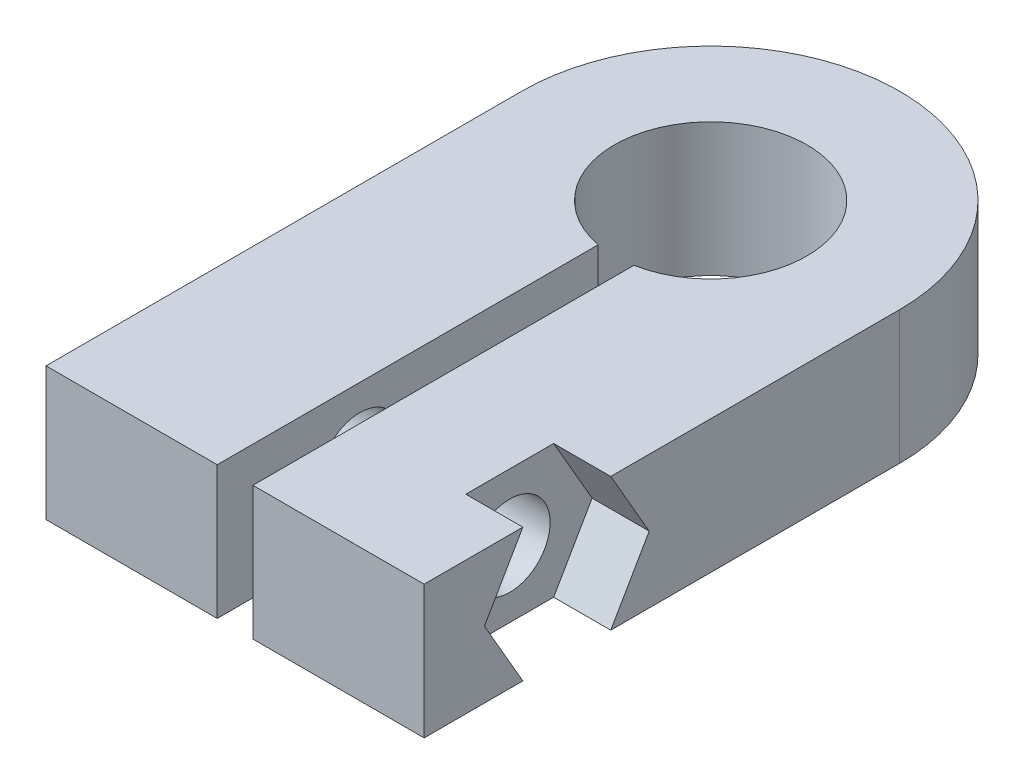
from build123d import *

# Parameters (mm, degrees)
BOSS_EXTRUDE1_DEPTH = 5.6
SKETCH2_R           = 1.7
CUT_EXTRUDE1_DEPTH  = 16.9
CUT_EXTRUDE2_DEPTH  = 2.4


with BuildPart() as part:
    # Sketch1 → Boss-Extrude1 (new body)
    with BuildSketch(Plane(origin=(0, 0, 0), x_dir=(1, 0, 0), z_dir=(0, 1, 0))):
        with BuildLine():
            Line((-7.95, -20), (-7.95, 0))
            ThreePointArc((-7.95, 0), (0, 7.95), (7.95, 0))
            Line((7.95, 0), (7.95, -20))
            Line((7.95, -20), (0.75, -20))
            Line((0.75, -20), (0.75, -3.979949748))
            ThreePointArc((0.75, -3.979949748), (0, 4.05), (-0.75, -3.979949748))
            Line((-0.75, -3.979949748), (-0.75, -20))
            Line((-0.75, -20), (-7.95, -20))
        make_face()
    extrude(amount=BOSS_EXTRUDE1_DEPTH)

    # Sketch2 → Cut-Extrude1 (cut, through all)
    with BuildSketch(Plane.ZY.offset(7.95)):
        with Locations((14, 2.8)):
            Circle(SKETCH2_R)
    extrude(amount=-CUT_EXTRUDE1_DEPTH, mode=Mode.SUBTRACT)

    # Sketch4 → Cut-Extrude2 (cut)
    with BuildSketch(Plane(origin=(7.95, 0, 0), x_dir=(0, 0, -1), z_dir=(1, 0, 0))):
        Polygon((-17.464101615, 2.8), (-15.847520861, 5.6), (-12.152479139, 5.6), (-10.535898385, 2.8), (-12.152479139, 0), (-15.847520861, 0), align=None)
    extrude(amount=-CUT_EXTRUDE2_DEPTH, mode=Mode.SUBTRACT)


solid = part.part
